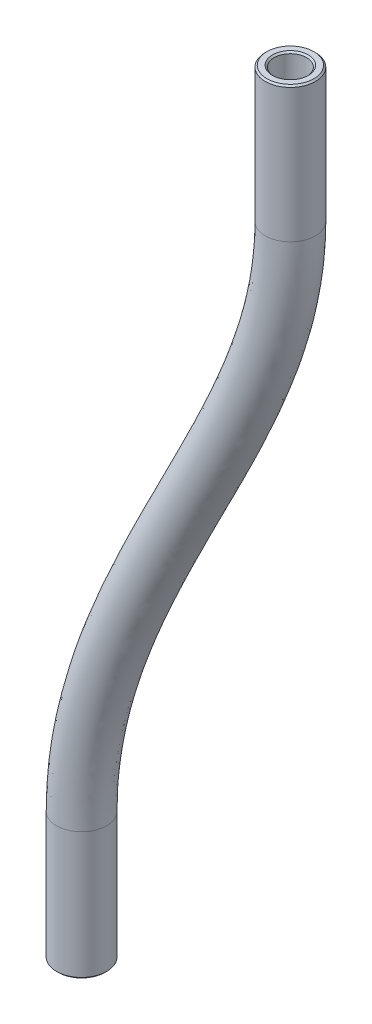
from build123d import *

# Parameters (mm, degrees)
SKETCH1_R     = 2
SKETCH1_R_2   = 1.3
CHAMFER1_SIZE = 0.127


with BuildPart() as part:
    # Sweep1: sweep along a curve in space
    with BuildLine() as sweep1_path:
        Line((-150.085279081, -93.282256564, 9.525), (-150.085279081, -103.482256564, 9.525))
        add(Edge.make_bspline(
            [(-135.847402149, -46.6, 7.098471947), (-135.847402149, -54.092565649, 7.098471947), (-142.966340615, -69.323468786, 8.311735973), (-150.085279081, -84.406424725, 9.525), (-150.085279081, -93.282256564, 9.525)],
            knots=[0, 0, 0, 0, 0.459991006, 1, 1, 1, 1], degree=3))
        Line((-135.847402149, -35.8, 7.098471947), (-135.847402149, -46.6, 7.098471947))
    # Sketch1 → Sweep1 (sweep)
    with BuildSketch(Plane(origin=(0, -95.382256564, 0), x_dir=(1, 0, 0), z_dir=(0, 1, 0))):
        with Locations((-150.085279081, -9.525)):
            Circle(SKETCH1_R)
        with Locations((-150.085279081, -9.525)):
            Circle(SKETCH1_R_2, mode=Mode.SUBTRACT)
    sweep(path=sweep1_path.line)

    # Chamfer1
    chamfer1_edges = [part.edges().sort_by_distance(p)[0] for p in [
        (-137.147402149, -35.8, 7.098471947),
        (-137.847402149, -35.8, 7.098471947),
        (-151.385279081, -103.482256564, 9.525),
        (-152.085279081, -103.482256564, 9.525),
    ]]
    chamfer(chamfer1_edges, length=CHAMFER1_SIZE)


solid = part.part
